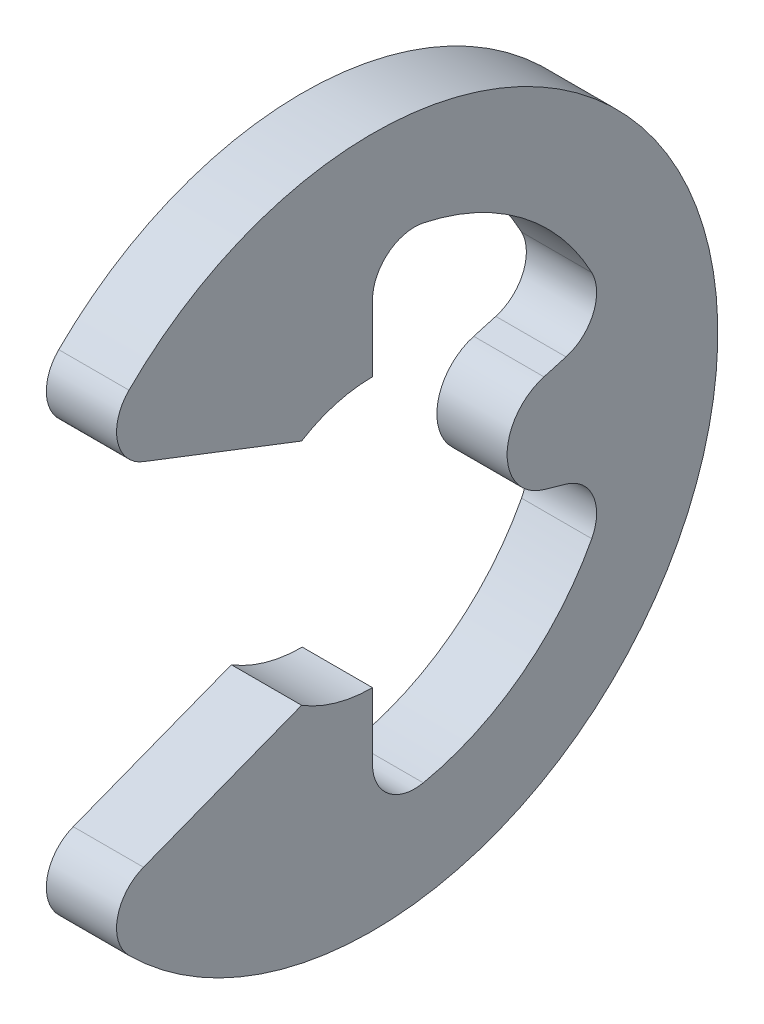
from build123d import *

# Parameters (mm, degrees)
EXTRUDE1_DEPTH          = 0.3
FILLET1_R               = 0.36
CUT_EXTRUDE1_DEPTH      = 5.182702476
CUT_EXTRUDE1_DEPTH_BACK = 5.182702476


with BuildPart() as part:
    # Sketch1 → Extrude1 (new, symmetric)
    with BuildSketch(Plane(origin=(0, 0, 0), x_dir=(0, 0, -1), z_dir=(1, 0, 0))):
        with BuildLine():
            Line((-2.42403204, -1.681240217), (-0.605800091, -0.9775))
            ThreePointArc((-0.605800091, -0.9775), (-0.314940471, -1.106034584), (0, -1.15))
            Line((0, -1.15), (0, -2.116129032))
            ThreePointArc((0, -2.116129032), (1.275078567, -1.68883887), (2.035227733, -0.579525803))
            Line((2.035227733, -0.579525803), (1.106034584, -0.314940471))
            ThreePointArc((1.106034584, -0.314940471), (1.15, 0), (1.106034584, 0.314940471))
            Line((1.106034584, 0.314940471), (2.035227733, 0.579525803))
            ThreePointArc((2.035227733, 0.579525803), (1.275078567, 1.68883887), (0, 2.116129032))
            Line((0, 2.116129032), (0, 1.15))
            ThreePointArc((0, 1.15), (-0.314940471, 1.106034584), (-0.605800091, 0.9775))
            Line((-0.605800091, 0.9775), (-2.42403204, 1.681240217))
            ThreePointArc((-2.42403204, 1.681240217), (2.95, 0), (-2.42403204, -1.681240217))
        make_face()
    extrude(amount=EXTRUDE1_DEPTH, both=True)

    # Fillet1
    fillet1_edges = [part.edges().sort_by_distance(p)[0] for p in [
        (0, -2.116129032, 0),
        (0, 2.116129032, 0),
        (0, -1.681240217, 2.42403204),
        (0, 1.681240217, 2.42403204),
        (0, -0.579525803, -2.035227733),
        (0, 0.579525803, -2.035227733),
    ]]
    fillet(fillet1_edges, radius=FILLET1_R)

    # Sketch4 → Cut-Extrude1 (cut, two sides: drawn at the far end of the back side and taken through both)
    with BuildSketch(Plane(origin=(0, 0, 0), x_dir=(0, 0, -1), z_dir=(1, 0, 0)).offset(-CUT_EXTRUDE1_DEPTH_BACK)):
        with BuildLine():
            ThreePointArc((1.15, 0), (1.138955612, -0.158997215), (1.106034584, -0.314940471))
            Line((1.106034584, -0.314940471), (1.464940471, -0.417137988))
            ThreePointArc((1.464940471, -0.417137988), (1.237576911, -0.26133867), (1.15, 0))
        make_face()
        with BuildLine():
            ThreePointArc((1.106034584, 0.314940471), (1.138955612, 0.158997215), (1.15, 0))
            ThreePointArc((1.15, 0), (1.237576911, 0.26133867), (1.464940471, 0.417137988))
            Line((1.464940471, 0.417137988), (1.106034584, 0.314940471))
        make_face()
    extrude(amount=CUT_EXTRUDE1_DEPTH + CUT_EXTRUDE1_DEPTH_BACK, mode=Mode.SUBTRACT)


solid = part.part
